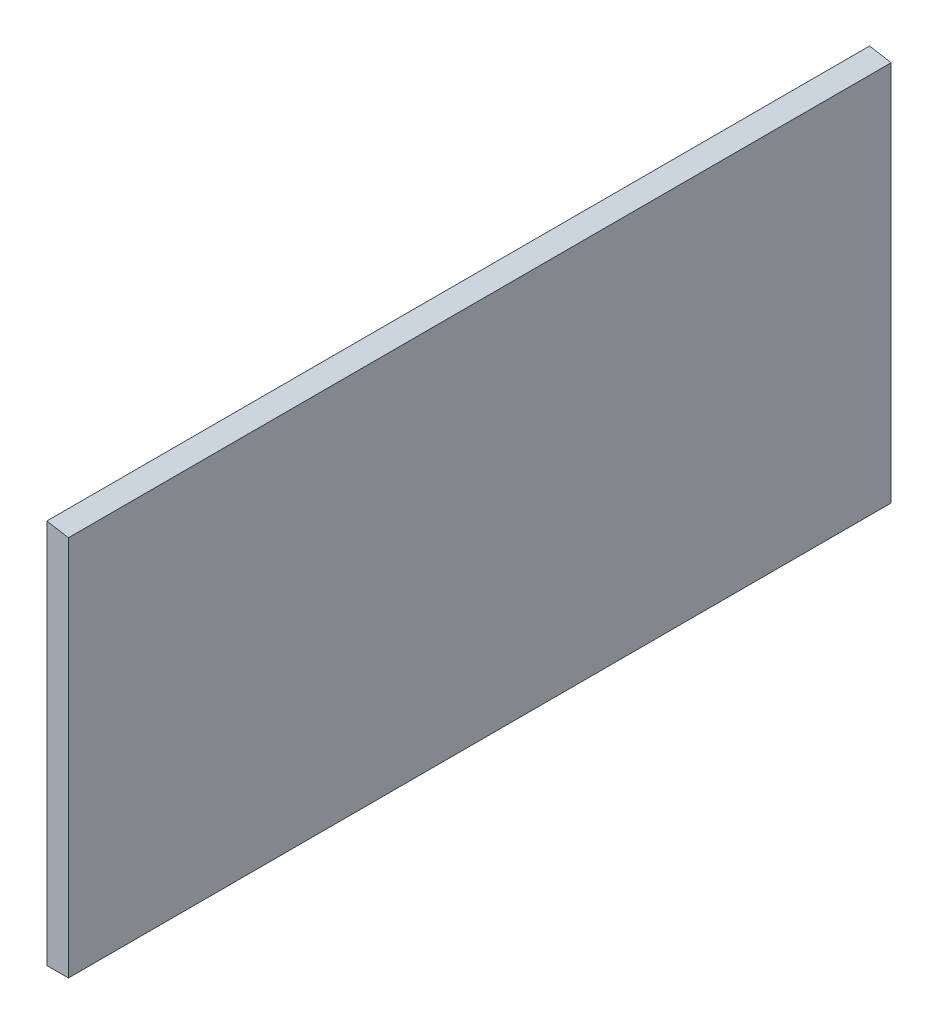
from build123d import *

# Parameters (mm, degrees)
BOSS_EXTRUDE1_DEPTH = 57.094


with BuildPart() as part:
    # Sketch1 → Boss-Extrude1 (new body, symmetric)
    with BuildSketch(Plane.XY):
        Polygon((3, 0), (3, 52.918568794), (0, 53.427995502), (0, 0), align=None)
    extrude(amount=BOSS_EXTRUDE1_DEPTH, both=True)


solid = part.part
